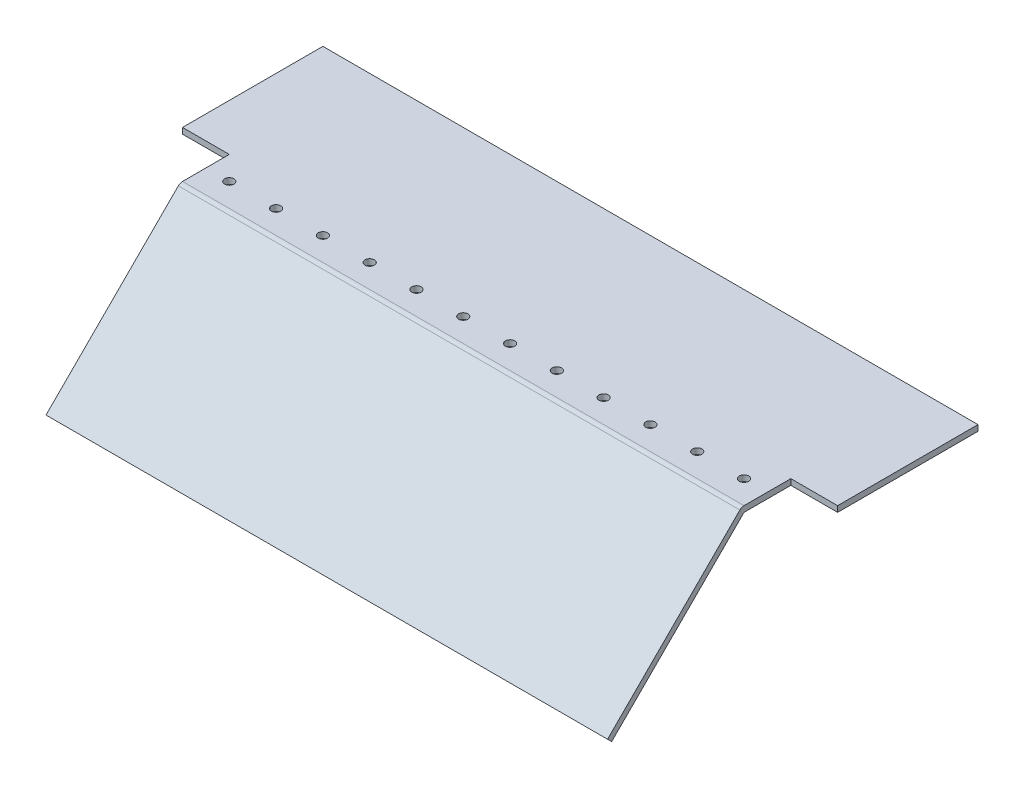
from build123d import *

# Parameters (mm, degrees)
INITIAL_MIDPLANE_EXTRUDE_DEPTH = 152.4
SKETCH1_3_W                    = 101.6
SKETCH1_3_H                    = 3.175
REEXTRUDE_FOR_WINGS_DEPTH      = 177.8
SKETCH2_W                      = 25.4
SKETCH2_H                      = 25.4
BANDSAW_CUT_DEPTH              = 219.089334072
SKETCH3_R                      = 2.54
INITIAL_MOUNTING_HOLE_DEPTH    = 219.089334072
MOUNTING_HOLE_PATTERN_COUNT    = 12
MOUNTING_HOLE_PATTERN_PITCH    = 25.4


with BuildPart() as part:
    # Sketch1 → Initial MidPlane Extrude (new, symmetric)
    with BuildSketch(Plane(origin=(0, 0, 0), x_dir=(0, 0, -1), z_dir=(1, 0, 0))):
        with BuildLine():
            ThreePointArc((0, 3.175), (-1.215019898, 2.933317516), (-2.24506403, 2.24506403))
            Line((-2.24506403, 2.24506403), (-74.087112999, -69.596984938))
            Line((-74.087112999, -69.596984938), (-71.842048969, -71.842048969))
            Line((-71.842048969, -71.842048969), (0, 0))
            Line((0, 0), (101.6, 0))
            Line((101.6, 0), (101.6, 3.175))
            Line((101.6, 3.175), (0, 3.175))
        make_face()
    extrude(amount=INITIAL_MIDPLANE_EXTRUDE_DEPTH, both=True)

    # Sketch1_3 → ReExtrude For Wings (add, symmetric)
    with BuildSketch(Plane(origin=(0, 0, 0), x_dir=(0, 0, -1), z_dir=(1, 0, 0))):
        with Locations((50.8, 1.5875)):
            Rectangle(SKETCH1_3_W, SKETCH1_3_H)
    extrude(amount=REEXTRUDE_FOR_WINGS_DEPTH, both=True)

    # Sketch2 → Bandsaw Cut (cut, through all)
    with BuildSketch(Plane(origin=(0, 3.175, 0), x_dir=(1, 0, 0), z_dir=(0, 1, 0))):
        with Locations((-165.1, 12.7)):
            Rectangle(SKETCH2_W, SKETCH2_H)
        with Locations((165.1, 12.7)):
            Rectangle(SKETCH2_W, SKETCH2_H)
    extrude(amount=-BANDSAW_CUT_DEPTH, mode=Mode.SUBTRACT)

    # Sketch3 → Initial Mounting Hole (cut, through all)
    with BuildSketch(Plane(origin=(0, 3.175, 0), x_dir=(1, 0, 0), z_dir=(0, 1, 0))):
        with Locations((-139.7, 12.7)):
            Circle(SKETCH3_R)
    initial_mounting_hole = extrude(amount=-INITIAL_MOUNTING_HOLE_DEPTH, mode=Mode.SUBTRACT)

    # Mounting Hole Pattern: Initial Mounting Hole ×12
    with Locations(*[(i * MOUNTING_HOLE_PATTERN_PITCH, 0, 0) for i in range(1, MOUNTING_HOLE_PATTERN_COUNT)]):
        add(initial_mounting_hole, mode=Mode.SUBTRACT)


solid = part.part
